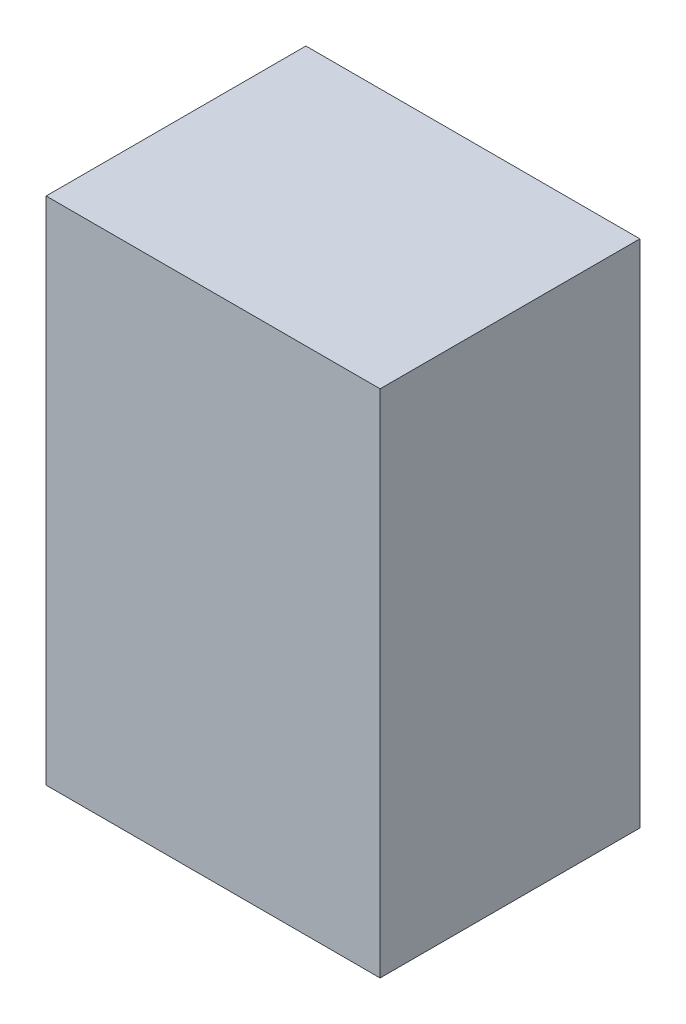
from build123d import *

# Parameters (mm, degrees)
SKETCH2_W           = 91.44
SKETCH2_H           = 71.12
BOSS_EXTRUDE1_DEPTH = 139.7


with BuildPart() as part:
    # Sketch2 → Boss-Extrude1 (new body)
    with BuildSketch(Plane(origin=(0, 0, 0), x_dir=(1, 0, 0), z_dir=(0, 1, 0))):
        Rectangle(SKETCH2_W, SKETCH2_H)
    extrude(amount=BOSS_EXTRUDE1_DEPTH)


solid = part.part
